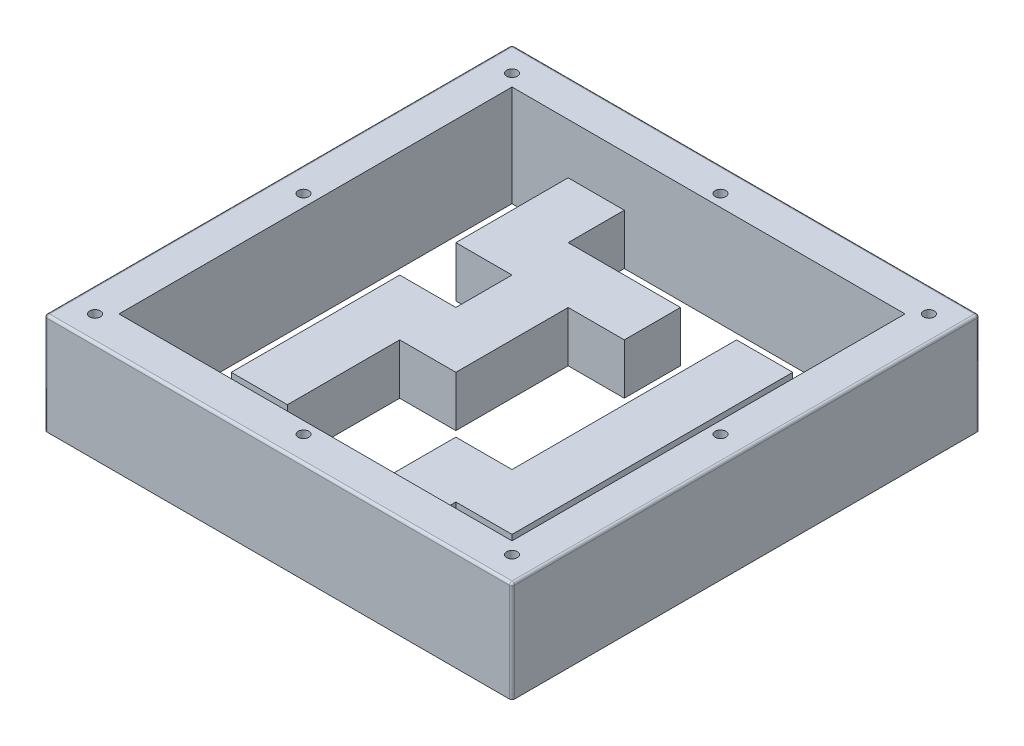
from build123d import *

# Parameters (mm, degrees)
ESQUISSE2_W             = 185
ESQUISSE2_H             = 185
BOSS_EXTRU_1_DEPTH      = 3
ESQUISSE3_W             = 185
ESQUISSE3_H             = 185
ESQUISSE3_W_2           = 155.54
ESQUISSE3_H_2           = 155.54
BOSS_EXTRU_2_DEPTH      = 40
BOSS_EXTRU_3_DEPTH      = 20
ENL_V_MAT_EXTRU_1_REACH = 5
ESQUISSE5_W             = 22.22
ESQUISSE5_H             = 22.22
ESQUISSE5_W_2           = 12.35
ESQUISSE5_H_2           = 12.35
CONG_1_R                = 1
ESQUISSE6_R             = 1.1
ENL_V_MAT_EXTRU_2_DEPTH = 44
ESQUISSE7_R             = 2.1
ENL_V_MAT_EXTRU_3_DEPTH = 41
ESQUISSE8_W             = 226.485362767
ESQUISSE8_H             = 20.409473883
ENL_V_MAT_EXTRU_4_DEPTH = 186
ESQUISSE9_R             = 2.1
ENL_V_MAT_EXTRU_5_DEPTH = 28


with BuildPart() as part:
    # Esquisse2 → Boss.-Extru.1 (new body)
    with BuildSketch(Plane(origin=(0, 0, 0), x_dir=(1, 0, 0), z_dir=(0, 1, 0))):
        Rectangle(ESQUISSE2_W, ESQUISSE2_H)
    extrude(amount=-BOSS_EXTRU_1_DEPTH)

    # Esquisse3 → Boss.-Extru.2 (add)
    with BuildSketch(Plane(origin=(0, 0, 0), x_dir=(1, 0, 0), z_dir=(0, 1, 0))):
        Rectangle(ESQUISSE3_W, ESQUISSE3_H)
        Rectangle(ESQUISSE3_W_2, ESQUISSE3_H_2, mode=Mode.SUBTRACT)
    extrude(amount=BOSS_EXTRU_2_DEPTH)

    # Esquisse4 → Boss.-Extru.3 (add)
    with BuildSketch(Plane(origin=(0, 0, 0), x_dir=(1, 0, 0), z_dir=(0, 1, 0))):
        Polygon((-55.55, 77.77), (-33.33, 77.77), (-33.33, 55.55), (11.11, 55.55), (11.11, 33.33), (-11.11, 33.33), (-11.11, -11.11), (-33.33, -11.11), (-33.33, -55.55), (-55.55, -55.55), (-55.55, 11.11), (-33.33, 11.11), (-33.33, 33.33), (-55.55, 33.33), align=None)
        Polygon((33.33, 55.55), (55.55, 55.55), (55.55, -55.55), (33.33, -55.55), (33.33, -77.77), (11.11, -77.77), (11.11, -33.33), (33.33, -33.33), align=None)
    extrude(amount=BOSS_EXTRU_3_DEPTH)

    # Esquisse5 → Enlèv. mat.-Extru.1 (cut, up to next)
    with BuildSketch(Plane(origin=(0, 0, 0), x_dir=(1, 0, 0), z_dir=(0, 1, 0)), mode=Mode.PRIVATE) as enl_v_mat_extru_1_sk1:
        with Locations((-22.22, 66.66)):
            Rectangle(ESQUISSE5_W, ESQUISSE5_H)
    enl_v_mat_extru_1_tool1 = extrude(enl_v_mat_extru_1_sk1.sketch, amount=-ENL_V_MAT_EXTRU_1_REACH, mode=Mode.PRIVATE) & part.part
    add(enl_v_mat_extru_1_tool1.solids().sort_by_distance((-22.22, 0, -66.66))[0], mode=Mode.SUBTRACT)
    # Esquisse5 → Enlèv. mat.-Extru.1 (cut, up to next)
    with BuildSketch(Plane(origin=(0, 0, 0), x_dir=(1, 0, 0), z_dir=(0, 1, 0)), mode=Mode.PRIVATE) as enl_v_mat_extru_1_sk2:
        with Locations((0, 22.22)):
            Rectangle(ESQUISSE5_W, ESQUISSE5_H)
    enl_v_mat_extru_1_tool2 = extrude(enl_v_mat_extru_1_sk2.sketch, amount=-ENL_V_MAT_EXTRU_1_REACH, mode=Mode.PRIVATE) & part.part
    add(enl_v_mat_extru_1_tool2.solids().sort_by_distance((0, 0, -22.22))[0], mode=Mode.SUBTRACT)
    # Esquisse5 → Enlèv. mat.-Extru.1 (cut, up to next)
    with BuildSketch(Plane(origin=(0, 0, 0), x_dir=(1, 0, 0), z_dir=(0, 1, 0)), mode=Mode.PRIVATE) as enl_v_mat_extru_1_sk3:
        with Locations((-27.155, -17.285)):
            Rectangle(ESQUISSE5_W_2, ESQUISSE5_H_2)
    enl_v_mat_extru_1_tool3 = extrude(enl_v_mat_extru_1_sk3.sketch, amount=-ENL_V_MAT_EXTRU_1_REACH, mode=Mode.PRIVATE) & part.part
    add(enl_v_mat_extru_1_tool3.solids().sort_by_distance((-27.155, 0, 17.285))[0], mode=Mode.SUBTRACT)
    # Esquisse5 → Enlèv. mat.-Extru.1 (cut, up to next)
    with BuildSketch(Plane(origin=(0, 0, 0), x_dir=(1, 0, 0), z_dir=(0, 1, 0)), mode=Mode.PRIVATE) as enl_v_mat_extru_1_sk4:
        with Locations((-66.66, 22.22)):
            Rectangle(ESQUISSE5_W_2, ESQUISSE5_H_2)
    enl_v_mat_extru_1_tool4 = extrude(enl_v_mat_extru_1_sk4.sketch, amount=-ENL_V_MAT_EXTRU_1_REACH, mode=Mode.PRIVATE) & part.part
    add(enl_v_mat_extru_1_tool4.solids().sort_by_distance((-66.66, 0, -22.22))[0], mode=Mode.SUBTRACT)
    # Esquisse5 → Enlèv. mat.-Extru.1 (cut, up to next)
    with BuildSketch(Plane(origin=(0, 0, 0), x_dir=(1, 0, 0), z_dir=(0, 1, 0)), mode=Mode.PRIVATE) as enl_v_mat_extru_1_sk5:
        with Locations((-66.66, -66.66)):
            Rectangle(ESQUISSE5_W_2, ESQUISSE5_H_2)
    enl_v_mat_extru_1_tool5 = extrude(enl_v_mat_extru_1_sk5.sketch, amount=-ENL_V_MAT_EXTRU_1_REACH, mode=Mode.PRIVATE) & part.part
    add(enl_v_mat_extru_1_tool5.solids().sort_by_distance((-66.66, 0, 66.66))[0], mode=Mode.SUBTRACT)
    # Esquisse5 → Enlèv. mat.-Extru.1 (cut, up to next)
    with BuildSketch(Plane(origin=(0, 0, 0), x_dir=(1, 0, 0), z_dir=(0, 1, 0)), mode=Mode.PRIVATE) as enl_v_mat_extru_1_sk6:
        with Locations((66.66, -66.66)):
            Rectangle(ESQUISSE5_W_2, ESQUISSE5_H_2)
    enl_v_mat_extru_1_tool6 = extrude(enl_v_mat_extru_1_sk6.sketch, amount=-ENL_V_MAT_EXTRU_1_REACH, mode=Mode.PRIVATE) & part.part
    add(enl_v_mat_extru_1_tool6.solids().sort_by_distance((66.66, 0, 66.66))[0], mode=Mode.SUBTRACT)
    # Esquisse5 → Enlèv. mat.-Extru.1 (cut, up to next)
    with BuildSketch(Plane(origin=(0, 0, 0), x_dir=(1, 0, 0), z_dir=(0, 1, 0)), mode=Mode.PRIVATE) as enl_v_mat_extru_1_sk7:
        with Locations((4.935, -49.375)):
            Rectangle(ESQUISSE5_W_2, ESQUISSE5_H_2)
    enl_v_mat_extru_1_tool7 = extrude(enl_v_mat_extru_1_sk7.sketch, amount=-ENL_V_MAT_EXTRU_1_REACH, mode=Mode.PRIVATE) & part.part
    add(enl_v_mat_extru_1_tool7.solids().sort_by_distance((4.935, 0, 49.375))[0], mode=Mode.SUBTRACT)

    # Congé1
    cong_1_edges = [part.edges().sort_by_distance(p)[0] for p in [
        (-92.5, 40, 0),
        (0, 40, 92.5),
        (92.5, 40, 0),
        (0, 40, -92.5),
        (-92.5, 18.5, -92.5),
        (92.5, 18.5, -92.5),
        (92.5, 18.5, 92.5),
        (-92.5, 18.5, 92.5),
    ]]
    fillet(cong_1_edges, radius=CONG_1_R)

    # Esquisse6 → Enlèv. mat.-Extru.2 (cut, through all)
    with BuildSketch(Plane(origin=(0, 40, 0), x_dir=(1, 0, 0), z_dir=(0, 1, 0))):
        with Locations(Location((-82.5, -82.5, 0), (0, 0, 270))):  # turned: the seam where the file's is
            Circle(ESQUISSE6_R)
        with Locations(Location((82.5, -82.5, 0), (0, 0, 270))):  # turned: the seam where the file's is
            Circle(ESQUISSE6_R)
        with Locations(Location((82.5, 82.5, 0), (0, 0, 270))):  # turned: the seam where the file's is
            Circle(ESQUISSE6_R)
        with Locations(Location((-82.5, 82.5, 0), (0, 0, 270))):  # turned: the seam where the file's is
            Circle(ESQUISSE6_R)
        with Locations(Location((0, 82.5, 0), (0, 0, 270))):  # turned: the seam where the file's is
            Circle(ESQUISSE6_R)
        with Locations(Location((82.5, 0, 0), (0, 0, 270))):  # turned: the seam where the file's is
            Circle(ESQUISSE6_R)
        with Locations(Location((-82.5, 0, 0), (0, 0, 270))):  # turned: the seam where the file's is
            Circle(ESQUISSE6_R)
        with Locations(Location((0, -82.5, 0), (0, 0, 270))):  # turned: the seam where the file's is
            Circle(ESQUISSE6_R)
    extrude(amount=-ENL_V_MAT_EXTRU_2_DEPTH, mode=Mode.SUBTRACT)

    # Esquisse7 → Enlèv. mat.-Extru.3 (cut)
    with BuildSketch(Plane(origin=(0, 40, 0), x_dir=(1, 0, 0), z_dir=(0, 1, 0))):
        with Locations(Location((-82.5, -82.5, 0), (0, 0, 270))):  # turned: the seam where the file's is
            Circle(ESQUISSE7_R)
        with Locations(Location((-82.5, 82.5, 0), (0, 0, 270))):  # turned: the seam where the file's is
            Circle(ESQUISSE7_R)
        with Locations(Location((82.5, 82.5, 0), (0, 0, 270))):  # turned: the seam where the file's is
            Circle(ESQUISSE7_R)
        with Locations(Location((82.5, -82.5, 0), (0, 0, 270))):  # turned: the seam where the file's is
            Circle(ESQUISSE7_R)
    extrude(amount=-ENL_V_MAT_EXTRU_3_DEPTH, mode=Mode.SUBTRACT)

    # Esquisse8 → Enlèv. mat.-Extru.4 (cut, through all)
    with BuildSketch(Plane.XY.offset(92.5)):
        with Locations((0.829347629, -10.204736942)):
            Rectangle(ESQUISSE8_W, ESQUISSE8_H)
    extrude(amount=-ENL_V_MAT_EXTRU_4_DEPTH, mode=Mode.SUBTRACT)

    # Esquisse9 → Enlèv. mat.-Extru.5 (cut)
    with BuildSketch(Plane(origin=(0, 40, 0), x_dir=(1, 0, 0), z_dir=(0, 1, 0))):
        with Locations(Location((0, 82.5, 0), (0, 0, 270))):  # turned: the seam where the file's is
            Circle(ESQUISSE9_R)
        with Locations(Location((82.5, 0, 0), (0, 0, 270))):  # turned: the seam where the file's is
            Circle(ESQUISSE9_R)
        with Locations(Location((0, -82.5, 0), (0, 0, 270))):  # turned: the seam where the file's is
            Circle(ESQUISSE9_R)
        with Locations(Location((-82.5, 0, 0), (0, 0, 270))):  # turned: the seam where the file's is
            Circle(ESQUISSE9_R)
    extrude(amount=-ENL_V_MAT_EXTRU_5_DEPTH, mode=Mode.SUBTRACT)


solid = part.part
